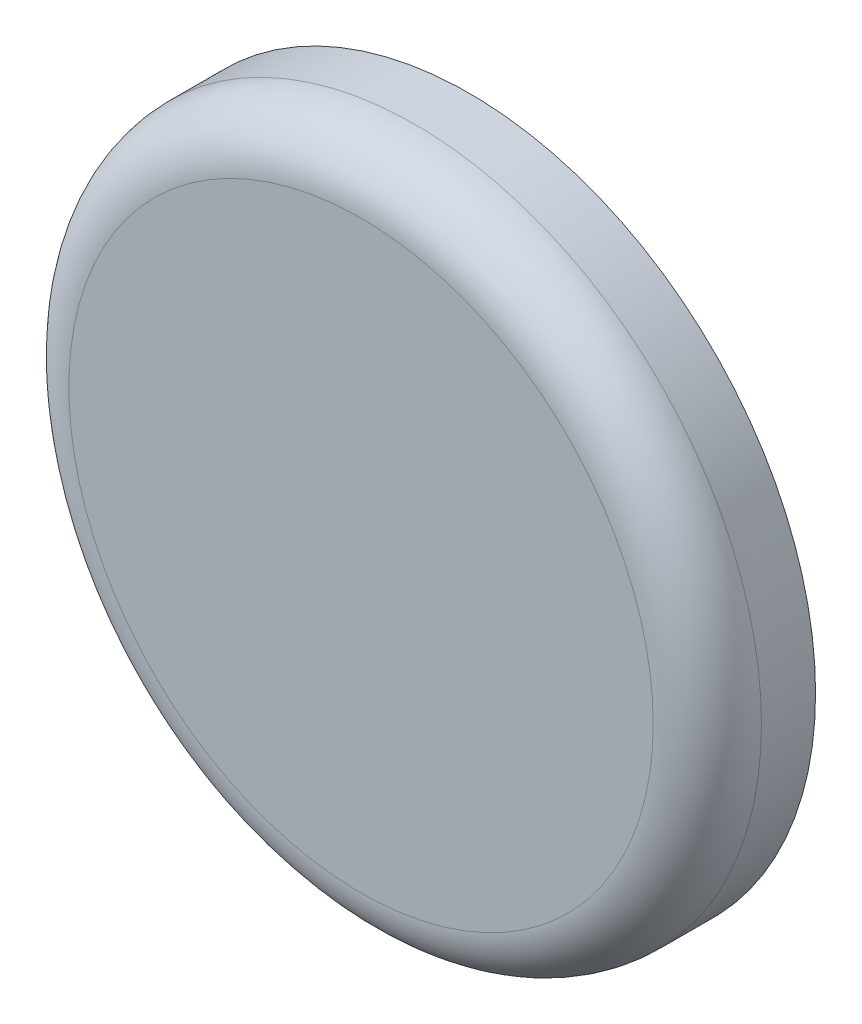
from build123d import *

# Parameters (mm, degrees)
ESBO_O1_R                = 32
RESSALTO_EXTRUS_O1_DEPTH = 10
FILETE1_R                = 5
ESBO_O2_R                = 27
CORTE_EXTRUS_O1_DEPTH    = 5


with BuildPart() as part:
    # Esboço1 → Ressalto-extrusão1 (new body)
    with BuildSketch(Plane.XY):
        Circle(ESBO_O1_R)
    extrude(amount=RESSALTO_EXTRUS_O1_DEPTH)

    # Filete1
    filete1_edges = [part.edges().sort_by_distance(p)[0] for p in [
        (-32, 0, 10),
    ]]
    fillet(filete1_edges, radius=FILETE1_R)

    # Esboço2 → Corte-extrusão1 (cut)
    with BuildSketch(Plane(origin=(0, 0, 0), x_dir=(-1, 0, 0), z_dir=(0, 0, -1))):
        Circle(ESBO_O2_R)
    extrude(amount=-CORTE_EXTRUS_O1_DEPTH, mode=Mode.SUBTRACT)


solid = part.part
